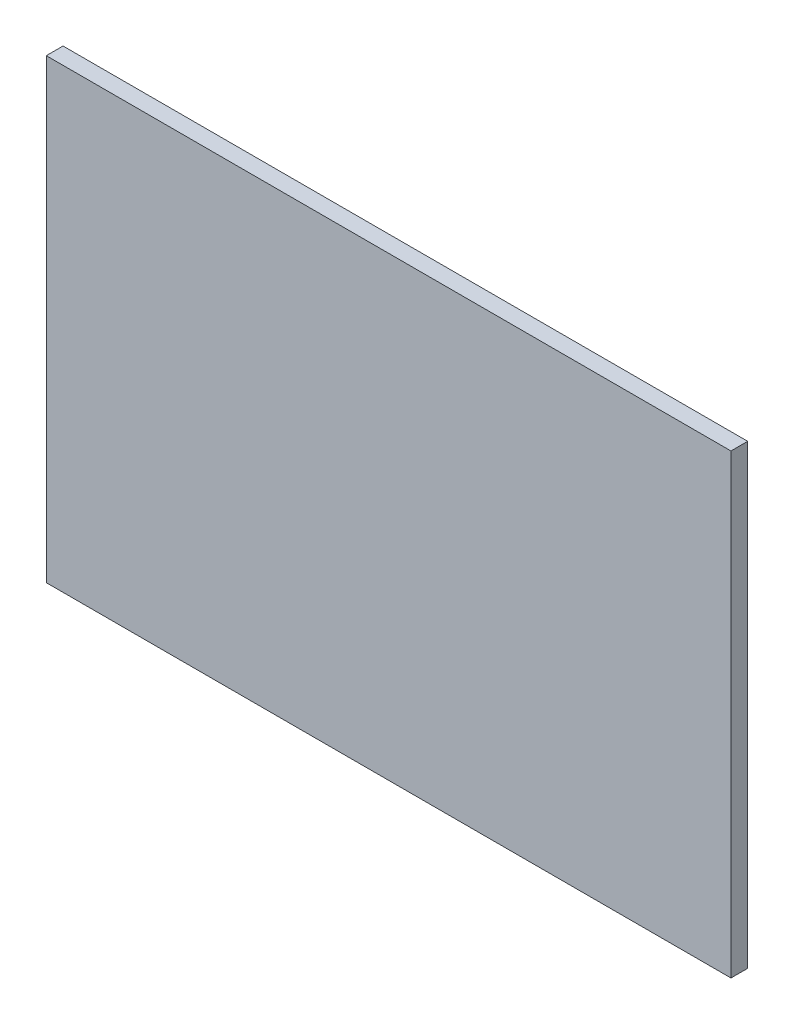
from build123d import *

# Parameters (mm, degrees)
SKETCH_1_W      = 45
SKETCH_1_H      = 30
EXTRUDE_1_DEPTH = 1.1


with BuildPart() as part:
    # 草图1 → 凸台-拉伸1 (new body)
    with BuildSketch(Plane.XY):
        Rectangle(SKETCH_1_W, SKETCH_1_H)
    extrude(amount=EXTRUDE_1_DEPTH)


solid = part.part
